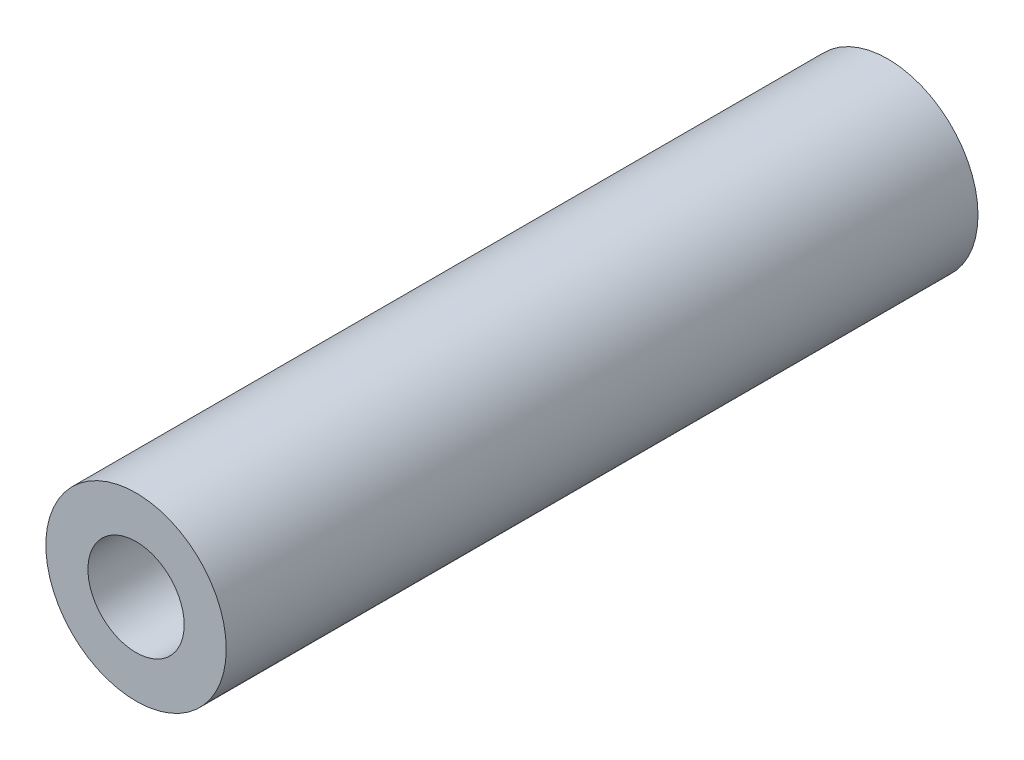
from build123d import *

# Parameters (mm, degrees)
SKETCH1_R           = 3
SKETCH1_R_2         = 1.6
EXTRUDE1_DEPTH      = 12.5
EXTRUDE1_DEPTH_BACK = 12.5


with BuildPart() as part:
    # Sketch1 → Extrude1 (new body, two sides)
    with BuildSketch(Plane.XY) as extrude1_sk:
        Circle(SKETCH1_R)
        Circle(SKETCH1_R_2, mode=Mode.SUBTRACT)
    extrude(amount=EXTRUDE1_DEPTH)
    extrude(extrude1_sk.sketch, amount=-EXTRUDE1_DEPTH_BACK)


solid = part.part
